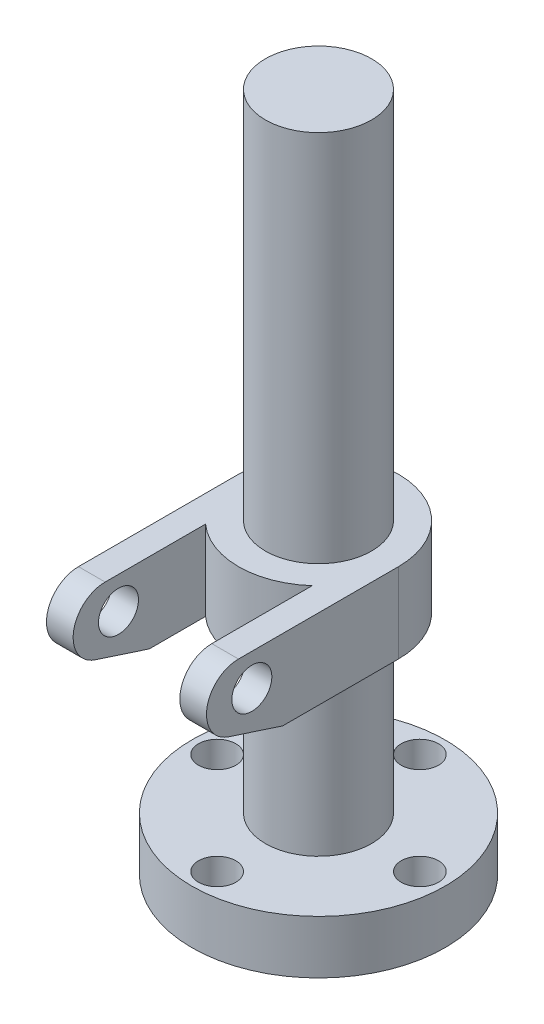
from build123d import *

# Parameters (mm, degrees)
SKETCH2_W           = 10
SKETCH2_H           = 80
BOSS_EXTRUDE1_DEPTH = 30
SKETCH3_R           = 7.5
CUT_EXTRUDE1_DEPTH  = 94
HOLE1_D             = 10
HOLE1_CBORE_D       = 14
HOLE1_CBORE_DEPTH   = 10
SKETCH8_R           = 20
CUT_EXTRUDE2_DEPTH  = 15


with BuildPart() as part:
    # Sketch1 → Revolve1 (revolve)
    with BuildSketch(Plane.XY):
        Polygon((0, 0), (47.5, 0), (47.5, 20), (19.9, 20), (19.9, 85), (30, 85), (30, 115), (19.9, 115), (19.9, 255), (0, 255), align=None)
    revolve(axis=Axis((0, 307.026159996, 0), (0, -1, 0)))

    # Sketch2 → Boss-Extrude1 (add)
    with BuildSketch(Plane(origin=(0, 85, 0), x_dir=(1, 0, 0), z_dir=(0, 1, 0))):
        with Locations((-25, -40)):
            Rectangle(SKETCH2_W, SKETCH2_H)
        with Locations((25, -40)):
            Rectangle(SKETCH2_W, SKETCH2_H)
    extrude(amount=BOSS_EXTRUDE1_DEPTH)

    # Sketch3 → Cut-Extrude1 (cut)
    with BuildSketch(Plane.ZY.offset(30)):
        with Locations((55, 103)):
            Circle(SKETCH3_R)
        with BuildLine():
            Line((43.44222057, 85), (63.709479612, 91.587736377))
            ThreePointArc((63.709479612, 91.587736377), (71.852155152, 104.877875997), (60, 115))
            Line((60, 115), (80, 115))
            Line((80, 115), (80, 85))
            Line((80, 85), (43.44222057, 85))
        make_face()
    extrude(amount=-CUT_EXTRUDE1_DEPTH, mode=Mode.SUBTRACT)

    # Hole1 (through all)
    with Locations(Plane(origin=(0, 20, 0), x_dir=(1, 0, 0), z_dir=(0, 1, 0))):
        with Locations((38, 0), (0, 38), (-38, 0), (0, -38)):
            CounterBoreHole(HOLE1_D / 2, HOLE1_CBORE_D / 2, HOLE1_CBORE_DEPTH)

    # Sketch8 → Cut-Extrude2 (cut)
    with BuildSketch(Plane.XZ):
        Circle(SKETCH8_R)
    extrude(amount=-CUT_EXTRUDE2_DEPTH, mode=Mode.SUBTRACT)


solid = part.part
